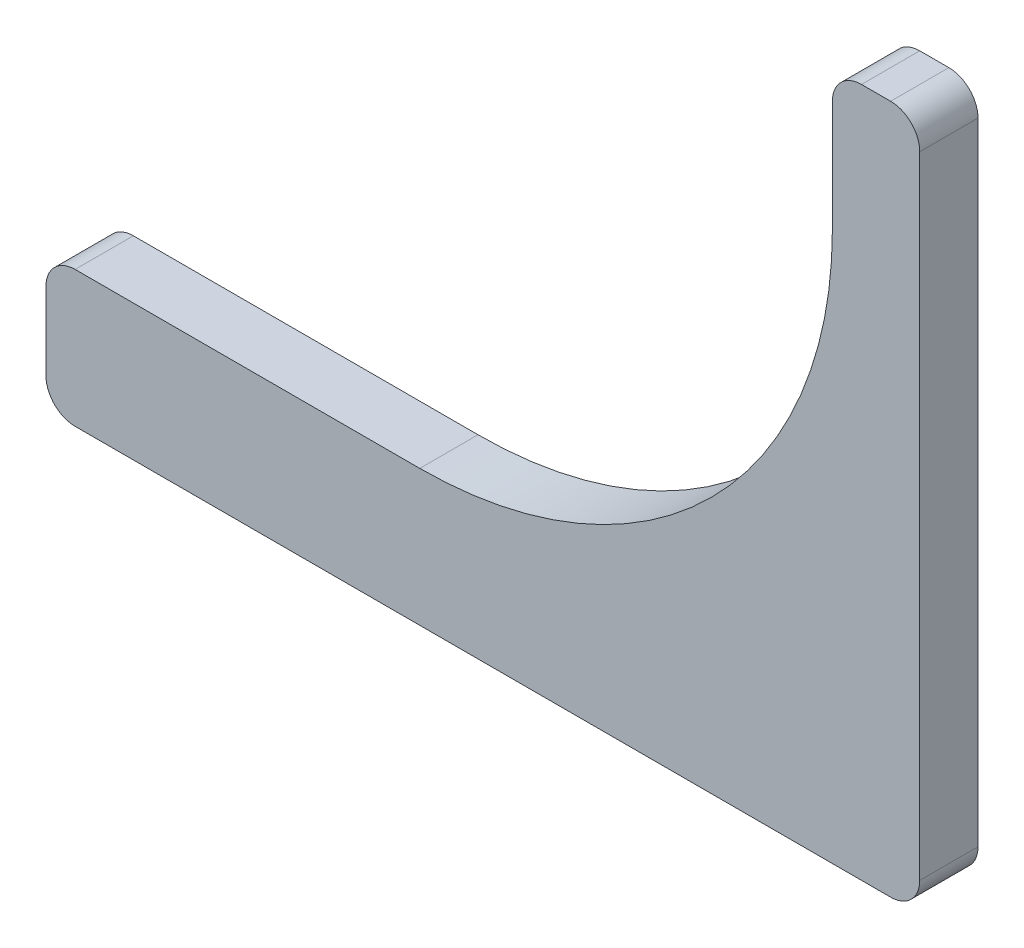
from build123d import *

# Parameters (mm, degrees)
EXTRUDE1_DEPTH = 6


with BuildPart() as part:
    # Sketch1 → Extrude1 (new body)
    with BuildSketch(Plane.XY):
        with BuildLine():
            Line((-35.5, -56.5), (48.5, -56.5))
            ThreePointArc((48.5, -56.5), (50.621320344, -55.621320344), (51.5, -53.5))
            Line((51.5, -53.5), (51.5, 11.5))
            ThreePointArc((51.5, 11.5), (50.621320344, 13.621320344), (48.5, 14.5))
            Line((48.5, 14.5), (45.5, 14.5))
            ThreePointArc((45.5, 14.5), (43.378679656, 13.621320344), (42.5, 11.5))
            Line((42.5, 11.5), (42.5, 0))
            ThreePointArc((42.5, 0), (30.0520382, -30.0520382), (0, -42.5))
            Line((0, -42.5), (-35.5, -42.5))
            ThreePointArc((-35.5, -42.5), (-37.621320344, -43.378679656), (-38.5, -45.5))
            Line((-38.5, -45.5), (-38.5, -53.5))
            ThreePointArc((-38.5, -53.5), (-37.621320344, -55.621320344), (-35.5, -56.5))
        make_face()
    extrude(amount=EXTRUDE1_DEPTH)


solid = part.part
